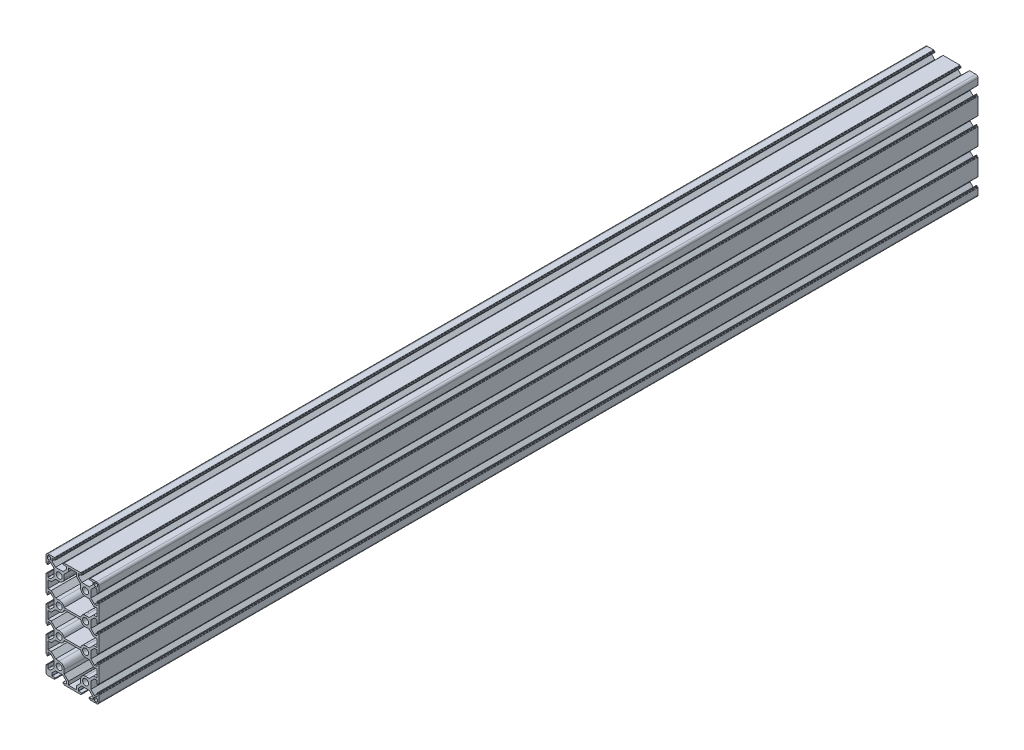
from build123d import *

# Parameters (mm, degrees)
SKETCH_1_R      = 3.4
EXTRUDE_1_DEPTH = 1000


with BuildPart() as part:
    # Эскиз1 → Бобышка-Вытянуть1 (new body)
    with BuildSketch(Plane.XY):
        with BuildLine():
            Line((-30, 38.25), (-30, 42.5))
            ThreePointArc((-30, 42.5), (-29.267766953, 44.267766953), (-27.5, 45))
            Line((-27.5, 45), (-23.25, 45))
            Line((-23.25, 45), (-20.5, 45))
            ThreePointArc((-20.5, 45), (-20.287867966, 44.912132034), (-20.2, 44.7))
            Line((-20.2, 44.7), (-20.2, 44.3))
            ThreePointArc((-20.2, 44.3), (-20.112132034, 44.087867966), (-19.9, 44))
            Line((-19.9, 44), (-19.4, 44))
            ThreePointArc((-19.4, 44), (-19.187867966, 43.912132034), (-19.1, 43.7))
            Line((-19.1, 43.7), (-19.1, 43.3))
            ThreePointArc((-19.1, 43.3), (-19.187867966, 43.087867966), (-19.4, 43))
            Line((-19.4, 43), (-22.95, 43))
            ThreePointArc((-22.95, 43), (-23.162132034, 42.912132034), (-23.25, 42.7))
            Line((-23.25, 42.7), (-23.25, 40.05))
            Line((-23.25, 40.05), (-19.2, 36))
            Line((-19.2, 36), (-10.8, 36))
            Line((-10.8, 36), (-6.75, 40.05))
            Line((-6.75, 40.05), (-6.75, 42.7))
            ThreePointArc((-6.75, 42.7), (-6.837867966, 42.912132034), (-7.05, 43))
            Line((-7.05, 43), (-10.6, 43))
            ThreePointArc((-10.6, 43), (-10.812132034, 43.087867966), (-10.9, 43.3))
            Line((-10.9, 43.3), (-10.9, 43.7))
            ThreePointArc((-10.9, 43.7), (-10.812132034, 43.912132034), (-10.6, 44))
            Line((-10.6, 44), (-10.1, 44))
            ThreePointArc((-10.1, 44), (-9.887867966, 44.087867966), (-9.8, 44.3))
            Line((-9.8, 44.3), (-9.8, 44.7))
            ThreePointArc((-9.8, 44.7), (-9.712132034, 44.912132034), (-9.5, 45))
            Line((-9.5, 45), (-6.75, 45))
            Line((-6.75, 45), (6.75, 45))
            Line((6.75, 45), (9.5, 45))
            ThreePointArc((9.5, 45), (9.712132034, 44.912132034), (9.8, 44.7))
            Line((9.8, 44.7), (9.8, 44.3))
            ThreePointArc((9.8, 44.3), (9.887867966, 44.087867966), (10.1, 44))
            Line((10.1, 44), (10.6, 44))
            ThreePointArc((10.6, 44), (10.812132034, 43.912132034), (10.9, 43.7))
            Line((10.9, 43.7), (10.9, 43.3))
            ThreePointArc((10.9, 43.3), (10.812132034, 43.087867966), (10.6, 43))
            Line((10.6, 43), (7.05, 43))
            ThreePointArc((7.05, 43), (6.837867966, 42.912132034), (6.75, 42.7))
            Line((6.75, 42.7), (6.75, 40.05))
            Line((6.75, 40.05), (10.8, 36))
            Line((10.8, 36), (19.2, 36))
            Line((19.2, 36), (23.25, 40.05))
            Line((23.25, 40.05), (23.25, 42.7))
            ThreePointArc((23.25, 42.7), (23.162132034, 42.912132034), (22.95, 43))
            Line((22.95, 43), (19.4, 43))
            ThreePointArc((19.4, 43), (19.187867966, 43.087867966), (19.1, 43.3))
            Line((19.1, 43.3), (19.1, 43.7))
            ThreePointArc((19.1, 43.7), (19.187867966, 43.912132034), (19.4, 44))
            Line((19.4, 44), (19.9, 44))
            ThreePointArc((19.9, 44), (20.112132034, 44.087867966), (20.2, 44.3))
            Line((20.2, 44.3), (20.2, 44.7))
            ThreePointArc((20.2, 44.7), (20.287867966, 44.912132034), (20.5, 45))
            Line((20.5, 45), (23.25, 45))
            Line((23.25, 45), (27.5, 45))
            ThreePointArc((27.5, 45), (29.267766953, 44.267766953), (30, 42.5))
            Line((30, 42.5), (30, 38.25))
            Line((30, 38.25), (30, 35.5))
            ThreePointArc((30, 35.5), (29.912132034, 35.287867966), (29.7, 35.2))
            Line((29.7, 35.2), (29.3, 35.2))
            ThreePointArc((29.3, 35.2), (29.087867966, 35.112132034), (29, 34.9))
            Line((29, 34.9), (29, 34.4))
            ThreePointArc((29, 34.4), (28.912132034, 34.187867966), (28.7, 34.1))
            Line((28.7, 34.1), (28.3, 34.1))
            ThreePointArc((28.3, 34.1), (28.087867966, 34.187867966), (28, 34.4))
            Line((28, 34.4), (28, 37.95))
            ThreePointArc((28, 37.95), (27.912132034, 38.162132034), (27.7, 38.25))
            Line((27.7, 38.25), (25.05, 38.25))
            Line((25.05, 38.25), (21, 34.2))
            Line((21, 34.2), (21, 25.8))
            Line((21, 25.8), (25.05, 21.75))
            Line((25.05, 21.75), (27.7, 21.75))
            ThreePointArc((27.7, 21.75), (27.912132034, 21.837867966), (28, 22.05))
            Line((28, 22.05), (28, 25.6))
            ThreePointArc((28, 25.6), (28.087867966, 25.812132034), (28.3, 25.9))
            Line((28.3, 25.9), (28.7, 25.9))
            ThreePointArc((28.7, 25.9), (28.912132034, 25.812132034), (29, 25.6))
            Line((29, 25.6), (29, 25.1))
            ThreePointArc((29, 25.1), (29.087867966, 24.887867966), (29.3, 24.8))
            Line((29.3, 24.8), (29.7, 24.8))
            ThreePointArc((29.7, 24.8), (29.912132034, 24.712132034), (30, 24.5))
            Line((30, 24.5), (30, 21.75))
            Line((30, 21.75), (30, 8.25))
            Line((30, 8.25), (30, 5.5))
            ThreePointArc((30, 5.5), (29.912132034, 5.287867966), (29.7, 5.2))
            Line((29.7, 5.2), (29.3, 5.2))
            ThreePointArc((29.3, 5.2), (29.087867966, 5.112132034), (29, 4.9))
            Line((29, 4.9), (29, 4.4))
            ThreePointArc((29, 4.4), (28.912132034, 4.187867966), (28.7, 4.1))
            Line((28.7, 4.1), (28.3, 4.1))
            ThreePointArc((28.3, 4.1), (28.087867966, 4.187867966), (28, 4.4))
            Line((28, 4.4), (28, 7.95))
            ThreePointArc((28, 7.95), (27.912132034, 8.162132034), (27.7, 8.25))
            Line((27.7, 8.25), (25.05, 8.25))
            Line((25.05, 8.25), (21, 4.2))
            Line((21, 4.2), (21, -4.2))
            Line((21, -4.2), (25.05, -8.25))
            Line((25.05, -8.25), (27.7, -8.25))
            ThreePointArc((27.7, -8.25), (27.912132034, -8.162132034), (28, -7.95))
            Line((28, -7.95), (28, -4.4))
            ThreePointArc((28, -4.4), (28.087867966, -4.187867966), (28.3, -4.1))
            Line((28.3, -4.1), (28.7, -4.1))
            ThreePointArc((28.7, -4.1), (28.912132034, -4.187867966), (29, -4.4))
            Line((29, -4.4), (29, -4.9))
            ThreePointArc((29, -4.9), (29.087867966, -5.112132034), (29.3, -5.2))
            Line((29.3, -5.2), (29.7, -5.2))
            ThreePointArc((29.7, -5.2), (29.912132034, -5.287867966), (30, -5.5))
            Line((30, -5.5), (30, -8.25))
            Line((30, -8.25), (30, -21.75))
            Line((30, -21.75), (30, -24.5))
            ThreePointArc((30, -24.5), (29.912132034, -24.712132034), (29.7, -24.8))
            Line((29.7, -24.8), (29.3, -24.8))
            ThreePointArc((29.3, -24.8), (29.087867966, -24.887867966), (29, -25.1))
            Line((29, -25.1), (29, -25.6))
            ThreePointArc((29, -25.6), (28.912132034, -25.812132034), (28.7, -25.9))
            Line((28.7, -25.9), (28.3, -25.9))
            ThreePointArc((28.3, -25.9), (28.087867966, -25.812132034), (28, -25.6))
            Line((28, -25.6), (28, -22.05))
            ThreePointArc((28, -22.05), (27.912132034, -21.837867966), (27.7, -21.75))
            Line((27.7, -21.75), (25.05, -21.75))
            Line((25.05, -21.75), (21, -25.8))
            Line((21, -25.8), (21, -34.2))
            Line((21, -34.2), (25.05, -38.25))
            Line((25.05, -38.25), (27.7, -38.25))
            ThreePointArc((27.7, -38.25), (27.912132034, -38.162132034), (28, -37.95))
            Line((28, -37.95), (28, -34.4))
            ThreePointArc((28, -34.4), (28.087867966, -34.187867966), (28.3, -34.1))
            Line((28.3, -34.1), (28.7, -34.1))
            ThreePointArc((28.7, -34.1), (28.912132034, -34.187867966), (29, -34.4))
            Line((29, -34.4), (29, -34.9))
            ThreePointArc((29, -34.9), (29.087867966, -35.112132034), (29.3, -35.2))
            Line((29.3, -35.2), (29.7, -35.2))
            ThreePointArc((29.7, -35.2), (29.912132034, -35.287867966), (30, -35.5))
            Line((30, -35.5), (30, -38.25))
            Line((30, -38.25), (30, -51.75))
            Line((30, -51.75), (30, -54.5))
            ThreePointArc((30, -54.5), (29.912132034, -54.712132034), (29.7, -54.8))
            Line((29.7, -54.8), (29.3, -54.8))
            ThreePointArc((29.3, -54.8), (29.087867966, -54.887867966), (29, -55.1))
            Line((29, -55.1), (29, -55.6))
            ThreePointArc((29, -55.6), (28.912132034, -55.812132034), (28.7, -55.9))
            Line((28.7, -55.9), (28.3, -55.9))
            ThreePointArc((28.3, -55.9), (28.087867966, -55.812132034), (28, -55.6))
            Line((28, -55.6), (28, -52.05))
            ThreePointArc((28, -52.05), (27.912132034, -51.837867966), (27.7, -51.75))
            Line((27.7, -51.75), (25.05, -51.75))
            Line((25.05, -51.75), (21, -55.8))
            Line((21, -55.8), (21, -64.2))
            Line((21, -64.2), (25.05, -68.25))
            Line((25.05, -68.25), (27.7, -68.25))
            ThreePointArc((27.7, -68.25), (27.912132034, -68.162132034), (28, -67.95))
            Line((28, -67.95), (28, -64.4))
            ThreePointArc((28, -64.4), (28.087867966, -64.187867966), (28.3, -64.1))
            Line((28.3, -64.1), (28.7, -64.1))
            ThreePointArc((28.7, -64.1), (28.912132034, -64.187867966), (29, -64.4))
            Line((29, -64.4), (29, -64.9))
            ThreePointArc((29, -64.9), (29.087867966, -65.112132034), (29.3, -65.2))
            Line((29.3, -65.2), (29.7, -65.2))
            ThreePointArc((29.7, -65.2), (29.912132034, -65.287867966), (30, -65.5))
            Line((30, -65.5), (30, -68.25))
            Line((30, -68.25), (30, -72.5))
            ThreePointArc((30, -72.5), (29.267766953, -74.267766953), (27.5, -75))
            Line((27.5, -75), (23.25, -75))
            Line((23.25, -75), (20.5, -75))
            ThreePointArc((20.5, -75), (20.287867966, -74.912132034), (20.2, -74.7))
            Line((20.2, -74.7), (20.2, -74.3))
            ThreePointArc((20.2, -74.3), (20.112132034, -74.087867966), (19.9, -74))
            Line((19.9, -74), (19.4, -74))
            ThreePointArc((19.4, -74), (19.187867966, -73.912132034), (19.1, -73.7))
            Line((19.1, -73.7), (19.1, -73.3))
            ThreePointArc((19.1, -73.3), (19.187867966, -73.087867966), (19.4, -73))
            Line((19.4, -73), (22.95, -73))
            ThreePointArc((22.95, -73), (23.162132034, -72.912132034), (23.25, -72.7))
            Line((23.25, -72.7), (23.25, -70.05))
            Line((23.25, -70.05), (19.2, -66))
            Line((19.2, -66), (10.8, -66))
            Line((10.8, -66), (6.75, -70.05))
            Line((6.75, -70.05), (6.75, -72.7))
            ThreePointArc((6.75, -72.7), (6.837867966, -72.912132034), (7.05, -73))
            Line((7.05, -73), (10.6, -73))
            ThreePointArc((10.6, -73), (10.812132034, -73.087867966), (10.9, -73.3))
            Line((10.9, -73.3), (10.9, -73.7))
            ThreePointArc((10.9, -73.7), (10.812132034, -73.912132034), (10.6, -74))
            Line((10.6, -74), (10.1, -74))
            ThreePointArc((10.1, -74), (9.887867966, -74.087867966), (9.8, -74.3))
            Line((9.8, -74.3), (9.8, -74.7))
            ThreePointArc((9.8, -74.7), (9.712132034, -74.912132034), (9.5, -75))
            Line((9.5, -75), (6.75, -75))
            Line((6.75, -75), (-6.75, -75))
            Line((-6.75, -75), (-9.5, -75))
            ThreePointArc((-9.5, -75), (-9.712132034, -74.912132034), (-9.8, -74.7))
            Line((-9.8, -74.7), (-9.8, -74.3))
            ThreePointArc((-9.8, -74.3), (-9.887867966, -74.087867966), (-10.1, -74))
            Line((-10.1, -74), (-10.6, -74))
            ThreePointArc((-10.6, -74), (-10.812132034, -73.912132034), (-10.9, -73.7))
            Line((-10.9, -73.7), (-10.9, -73.3))
            ThreePointArc((-10.9, -73.3), (-10.812132034, -73.087867966), (-10.6, -73))
            Line((-10.6, -73), (-7.05, -73))
            ThreePointArc((-7.05, -73), (-6.837867966, -72.912132034), (-6.75, -72.7))
            Line((-6.75, -72.7), (-6.75, -70.05))
            Line((-6.75, -70.05), (-10.8, -66))
            Line((-10.8, -66), (-19.2, -66))
            Line((-19.2, -66), (-23.25, -70.05))
            Line((-23.25, -70.05), (-23.25, -72.7))
            ThreePointArc((-23.25, -72.7), (-23.162132034, -72.912132034), (-22.95, -73))
            Line((-22.95, -73), (-19.4, -73))
            ThreePointArc((-19.4, -73), (-19.187867966, -73.087867966), (-19.1, -73.3))
            Line((-19.1, -73.3), (-19.1, -73.7))
            ThreePointArc((-19.1, -73.7), (-19.187867966, -73.912132034), (-19.4, -74))
            Line((-19.4, -74), (-19.9, -74))
            ThreePointArc((-19.9, -74), (-20.112132034, -74.087867966), (-20.2, -74.3))
            Line((-20.2, -74.3), (-20.2, -74.7))
            ThreePointArc((-20.2, -74.7), (-20.287867966, -74.912132034), (-20.5, -75))
            Line((-20.5, -75), (-23.25, -75))
            Line((-23.25, -75), (-27.5, -75))
            ThreePointArc((-27.5, -75), (-29.267766953, -74.267766953), (-30, -72.5))
            Line((-30, -72.5), (-30, -68.25))
            Line((-30, -68.25), (-30, -65.5))
            ThreePointArc((-30, -65.5), (-29.912132034, -65.287867966), (-29.7, -65.2))
            Line((-29.7, -65.2), (-29.3, -65.2))
            ThreePointArc((-29.3, -65.2), (-29.087867966, -65.112132034), (-29, -64.9))
            Line((-29, -64.9), (-29, -64.4))
            ThreePointArc((-29, -64.4), (-28.912132034, -64.187867966), (-28.7, -64.1))
            Line((-28.7, -64.1), (-28.3, -64.1))
            ThreePointArc((-28.3, -64.1), (-28.087867966, -64.187867966), (-28, -64.4))
            Line((-28, -64.4), (-28, -67.95))
            ThreePointArc((-28, -67.95), (-27.912132034, -68.162132034), (-27.7, -68.25))
            Line((-27.7, -68.25), (-25.05, -68.25))
            Line((-25.05, -68.25), (-21, -64.2))
            Line((-21, -64.2), (-21, -55.8))
            Line((-21, -55.8), (-25.05, -51.75))
            Line((-25.05, -51.75), (-27.7, -51.75))
            ThreePointArc((-27.7, -51.75), (-27.912132034, -51.837867966), (-28, -52.05))
            Line((-28, -52.05), (-28, -55.6))
            ThreePointArc((-28, -55.6), (-28.087867966, -55.812132034), (-28.3, -55.9))
            Line((-28.3, -55.9), (-28.7, -55.9))
            ThreePointArc((-28.7, -55.9), (-28.912132034, -55.812132034), (-29, -55.6))
            Line((-29, -55.6), (-29, -55.1))
            ThreePointArc((-29, -55.1), (-29.087867966, -54.887867966), (-29.3, -54.8))
            Line((-29.3, -54.8), (-29.7, -54.8))
            ThreePointArc((-29.7, -54.8), (-29.912132034, -54.712132034), (-30, -54.5))
            Line((-30, -54.5), (-30, -51.75))
            Line((-30, -51.75), (-30, -38.25))
            Line((-30, -38.25), (-30, -35.5))
            ThreePointArc((-30, -35.5), (-29.912132034, -35.287867966), (-29.7, -35.2))
            Line((-29.7, -35.2), (-29.3, -35.2))
            ThreePointArc((-29.3, -35.2), (-29.087867966, -35.112132034), (-29, -34.9))
            Line((-29, -34.9), (-29, -34.4))
            ThreePointArc((-29, -34.4), (-28.912132034, -34.187867966), (-28.7, -34.1))
            Line((-28.7, -34.1), (-28.3, -34.1))
            ThreePointArc((-28.3, -34.1), (-28.087867966, -34.187867966), (-28, -34.4))
            Line((-28, -34.4), (-28, -37.95))
            ThreePointArc((-28, -37.95), (-27.912132034, -38.162132034), (-27.7, -38.25))
            Line((-27.7, -38.25), (-25.05, -38.25))
            Line((-25.05, -38.25), (-21, -34.2))
            Line((-21, -34.2), (-21, -25.8))
            Line((-21, -25.8), (-25.05, -21.75))
            Line((-25.05, -21.75), (-27.7, -21.75))
            ThreePointArc((-27.7, -21.75), (-27.912132034, -21.837867966), (-28, -22.05))
            Line((-28, -22.05), (-28, -25.6))
            ThreePointArc((-28, -25.6), (-28.087867966, -25.812132034), (-28.3, -25.9))
            Line((-28.3, -25.9), (-28.7, -25.9))
            ThreePointArc((-28.7, -25.9), (-28.912132034, -25.812132034), (-29, -25.6))
            Line((-29, -25.6), (-29, -25.1))
            ThreePointArc((-29, -25.1), (-29.087867966, -24.887867966), (-29.3, -24.8))
            Line((-29.3, -24.8), (-29.7, -24.8))
            ThreePointArc((-29.7, -24.8), (-29.912132034, -24.712132034), (-30, -24.5))
            Line((-30, -24.5), (-30, -21.75))
            Line((-30, -21.75), (-30, -8.25))
            Line((-30, -8.25), (-30, -5.5))
            ThreePointArc((-30, -5.5), (-29.912132034, -5.287867966), (-29.7, -5.2))
            Line((-29.7, -5.2), (-29.3, -5.2))
            ThreePointArc((-29.3, -5.2), (-29.087867966, -5.112132034), (-29, -4.9))
            Line((-29, -4.9), (-29, -4.4))
            ThreePointArc((-29, -4.4), (-28.912132034, -4.187867966), (-28.7, -4.1))
            Line((-28.7, -4.1), (-28.3, -4.1))
            ThreePointArc((-28.3, -4.1), (-28.087867966, -4.187867966), (-28, -4.4))
            Line((-28, -4.4), (-28, -7.95))
            ThreePointArc((-28, -7.95), (-27.912132034, -8.162132034), (-27.7, -8.25))
            Line((-27.7, -8.25), (-25.05, -8.25))
            Line((-25.05, -8.25), (-21, -4.2))
            Line((-21, -4.2), (-21, 4.2))
            Line((-21, 4.2), (-25.05, 8.25))
            Line((-25.05, 8.25), (-27.7, 8.25))
            ThreePointArc((-27.7, 8.25), (-27.912132034, 8.162132034), (-28, 7.95))
            Line((-28, 7.95), (-28, 4.4))
            ThreePointArc((-28, 4.4), (-28.087867966, 4.187867966), (-28.3, 4.1))
            Line((-28.3, 4.1), (-28.7, 4.1))
            ThreePointArc((-28.7, 4.1), (-28.912132034, 4.187867966), (-29, 4.4))
            Line((-29, 4.4), (-29, 4.9))
            ThreePointArc((-29, 4.9), (-29.087867966, 5.112132034), (-29.3, 5.2))
            Line((-29.3, 5.2), (-29.7, 5.2))
            ThreePointArc((-29.7, 5.2), (-29.912132034, 5.287867966), (-30, 5.5))
            Line((-30, 5.5), (-30, 8.25))
            Line((-30, 8.25), (-30, 21.75))
            Line((-30, 21.75), (-30, 24.5))
            ThreePointArc((-30, 24.5), (-29.912132034, 24.712132034), (-29.7, 24.8))
            Line((-29.7, 24.8), (-29.3, 24.8))
            ThreePointArc((-29.3, 24.8), (-29.087867966, 24.887867966), (-29, 25.1))
            Line((-29, 25.1), (-29, 25.6))
            ThreePointArc((-29, 25.6), (-28.912132034, 25.812132034), (-28.7, 25.9))
            Line((-28.7, 25.9), (-28.3, 25.9))
            ThreePointArc((-28.3, 25.9), (-28.087867966, 25.812132034), (-28, 25.6))
            Line((-28, 25.6), (-28, 22.05))
            ThreePointArc((-28, 22.05), (-27.912132034, 21.837867966), (-27.7, 21.75))
            Line((-27.7, 21.75), (-25.05, 21.75))
            Line((-25.05, 21.75), (-21, 25.8))
            Line((-21, 25.8), (-21, 34.2))
            Line((-21, 34.2), (-25.05, 38.25))
            Line((-25.05, 38.25), (-27.7, 38.25))
            ThreePointArc((-27.7, 38.25), (-27.912132034, 38.162132034), (-28, 37.95))
            Line((-28, 37.95), (-28, 34.4))
            ThreePointArc((-28, 34.4), (-28.087867966, 34.187867966), (-28.3, 34.1))
            Line((-28.3, 34.1), (-28.7, 34.1))
            ThreePointArc((-28.7, 34.1), (-28.912132034, 34.187867966), (-29, 34.4))
            Line((-29, 34.4), (-29, 34.9))
            ThreePointArc((-29, 34.9), (-29.087867966, 35.112132034), (-29.3, 35.2))
            Line((-29.3, 35.2), (-29.7, 35.2))
            ThreePointArc((-29.7, 35.2), (-29.912132034, 35.287867966), (-30, 35.5))
            Line((-30, 35.5), (-30, 38.25))
        make_face()
        with Locations((-15, 30)):
            Circle(SKETCH_1_R, mode=Mode.SUBTRACT)
        with Locations((-15, 0)):
            Circle(SKETCH_1_R, mode=Mode.SUBTRACT)
        with Locations((15, 30)):
            Circle(SKETCH_1_R, mode=Mode.SUBTRACT)
        with Locations((15, 0)):
            Circle(SKETCH_1_R, mode=Mode.SUBTRACT)
        with Locations((-15, -30)):
            Circle(SKETCH_1_R, mode=Mode.SUBTRACT)
        with Locations((15, -30)):
            Circle(SKETCH_1_R, mode=Mode.SUBTRACT)
        with Locations((-15, -60)):
            Circle(SKETCH_1_R, mode=Mode.SUBTRACT)
        with Locations((15, -60)):
            Circle(SKETCH_1_R, mode=Mode.SUBTRACT)
        with BuildLine():
            Line((4.5, 42.8), (-4.5, 42.8))
            Line((-4.5, 42.8), (-4.5, 38.90588745))
            Line((-4.5, 38.90588745), (-9.3, 34.10588745))
            Line((-9.3, 34.10588745), (-9.3, 30))
            ThreePointArc((-9.3, 30), (-10.969491347, 25.969491347), (-15, 24.3))
            Line((-15, 24.3), (-19.10588745, 24.3))
            Line((-19.10588745, 24.3), (-24.05588745, 19.35))
            Line((-24.05588745, 19.35), (-27.8, 19.35))
            Line((-27.8, 19.35), (-27.8, 10.65))
            Line((-27.8, 10.65), (-24.05588745, 10.65))
            Line((-24.05588745, 10.65), (-19.10588745, 5.7))
            Line((-19.10588745, 5.7), (-15, 5.7))
            ThreePointArc((-15, 5.7), (-11.379226602, 4.402272141), (-9.407147418, 1.1))
            Line((-9.407147418, 1.1), (9.407147418, 1.1))
            ThreePointArc((9.407147418, 1.1), (11.379226602, 4.402272141), (15, 5.7))
            Line((15, 5.7), (19.10588745, 5.7))
            Line((19.10588745, 5.7), (24.05588745, 10.65))
            Line((24.05588745, 10.65), (27.8, 10.65))
            Line((27.8, 10.65), (27.8, 19.35))
            Line((27.8, 19.35), (24.05588745, 19.35))
            Line((24.05588745, 19.35), (19.10588745, 24.3))
            Line((19.10588745, 24.3), (15, 24.3))
            ThreePointArc((15, 24.3), (10.969491347, 25.969491347), (9.3, 30))
            Line((9.3, 30), (9.3, 34.10588745))
            Line((9.3, 34.10588745), (4.5, 38.90588745))
            Line((4.5, 38.90588745), (4.5, 42.8))
        make_face(mode=Mode.SUBTRACT)
        with BuildLine():
            Line((-27.35, 43.55), (-25.95, 43.55))
            ThreePointArc((-25.95, 43.55), (-25.101471863, 43.198528137), (-24.75, 42.35))
            Line((-24.75, 42.35), (-24.75, 40.95))
            ThreePointArc((-24.75, 40.95), (-25.101471863, 40.101471863), (-25.95, 39.75))
            Line((-25.95, 39.75), (-27.35, 39.75))
            ThreePointArc((-27.35, 39.75), (-28.198528137, 40.101471863), (-28.55, 40.95))
            Line((-28.55, 40.95), (-28.55, 42.35))
            ThreePointArc((-28.55, 42.35), (-28.198528137, 43.198528137), (-27.35, 43.55))
        make_face(mode=Mode.SUBTRACT)
        with BuildLine():
            Line((27.35, 43.55), (25.95, 43.55))
            ThreePointArc((25.95, 43.55), (25.101471863, 43.198528137), (24.75, 42.35))
            Line((24.75, 42.35), (24.75, 40.95))
            ThreePointArc((24.75, 40.95), (25.101471863, 40.101471863), (25.95, 39.75))
            Line((25.95, 39.75), (27.35, 39.75))
            ThreePointArc((27.35, 39.75), (28.198528137, 40.101471863), (28.55, 40.95))
            Line((28.55, 40.95), (28.55, 42.35))
            ThreePointArc((28.55, 42.35), (28.198528137, 43.198528137), (27.35, 43.55))
        make_face(mode=Mode.SUBTRACT)
        with BuildLine():
            Line((-9.407147418, -28.9), (9.407147418, -28.9))
            ThreePointArc((9.407147418, -28.9), (11.379226602, -25.597727859), (15, -24.3))
            Line((15, -24.3), (19.10588745, -24.3))
            Line((19.10588745, -24.3), (24.05588745, -19.35))
            Line((24.05588745, -19.35), (27.8, -19.35))
            Line((27.8, -19.35), (27.8, -10.65))
            Line((27.8, -10.65), (24.05588745, -10.65))
            Line((24.05588745, -10.65), (19.10588745, -5.7))
            Line((19.10588745, -5.7), (15, -5.7))
            ThreePointArc((15, -5.7), (11.379226602, -4.402272141), (9.407147418, -1.1))
            Line((9.407147418, -1.1), (-9.407147418, -1.1))
            ThreePointArc((-9.407147418, -1.1), (-11.379226602, -4.402272141), (-15, -5.7))
            Line((-15, -5.7), (-19.10588745, -5.7))
            Line((-19.10588745, -5.7), (-24.05588745, -10.65))
            Line((-24.05588745, -10.65), (-27.8, -10.65))
            Line((-27.8, -10.65), (-27.8, -19.35))
            Line((-27.8, -19.35), (-24.05588745, -19.35))
            Line((-24.05588745, -19.35), (-19.10588745, -24.3))
            Line((-19.10588745, -24.3), (-15, -24.3))
            ThreePointArc((-15, -24.3), (-11.379226602, -25.597727859), (-9.407147418, -28.9))
        make_face(mode=Mode.SUBTRACT)
        with BuildLine():
            Line((28.55, -72.35), (28.55, -70.95))
            ThreePointArc((28.55, -70.95), (28.198528137, -70.101471863), (27.35, -69.75))
            Line((27.35, -69.75), (25.95, -69.75))
            ThreePointArc((25.95, -69.75), (25.101471863, -70.101471863), (24.75, -70.95))
            Line((24.75, -70.95), (24.75, -72.35))
            ThreePointArc((24.75, -72.35), (25.101471863, -73.198528137), (25.95, -73.55))
            Line((25.95, -73.55), (27.35, -73.55))
            ThreePointArc((27.35, -73.55), (28.198528137, -73.198528137), (28.55, -72.35))
        make_face(mode=Mode.SUBTRACT)
        with BuildLine():
            Line((27.8, -40.65), (24.05588745, -40.65))
            Line((24.05588745, -40.65), (19.10588745, -35.7))
            Line((19.10588745, -35.7), (15, -35.7))
            ThreePointArc((15, -35.7), (11.379226602, -34.402272141), (9.407147418, -31.1))
            Line((9.407147418, -31.1), (-9.407147418, -31.1))
            ThreePointArc((-9.407147418, -31.1), (-11.379226602, -34.402272141), (-15, -35.7))
            Line((-15, -35.7), (-19.10588745, -35.7))
            Line((-19.10588745, -35.7), (-24.05588745, -40.65))
            Line((-24.05588745, -40.65), (-27.8, -40.65))
            Line((-27.8, -40.65), (-27.8, -49.35))
            Line((-27.8, -49.35), (-24.05588745, -49.35))
            Line((-24.05588745, -49.35), (-19.10588745, -54.3))
            Line((-19.10588745, -54.3), (-15, -54.3))
            ThreePointArc((-15, -54.3), (-10.969491347, -55.969491347), (-9.3, -60))
            Line((-9.3, -60), (-9.3, -64.10588745))
            Line((-9.3, -64.10588745), (-4.5, -68.90588745))
            Line((-4.5, -68.90588745), (-4.5, -72.8))
            Line((-4.5, -72.8), (4.5, -72.8))
            Line((4.5, -72.8), (4.5, -68.90588745))
            Line((4.5, -68.90588745), (9.3, -64.10588745))
            Line((9.3, -64.10588745), (9.3, -60))
            ThreePointArc((9.3, -60), (10.969491347, -55.969491347), (15, -54.3))
            Line((15, -54.3), (19.10588745, -54.3))
            Line((19.10588745, -54.3), (24.05588745, -49.35))
            Line((24.05588745, -49.35), (27.8, -49.35))
            Line((27.8, -49.35), (27.8, -40.65))
        make_face(mode=Mode.SUBTRACT)
    extrude(amount=EXTRUDE_1_DEPTH)


solid = part.part
